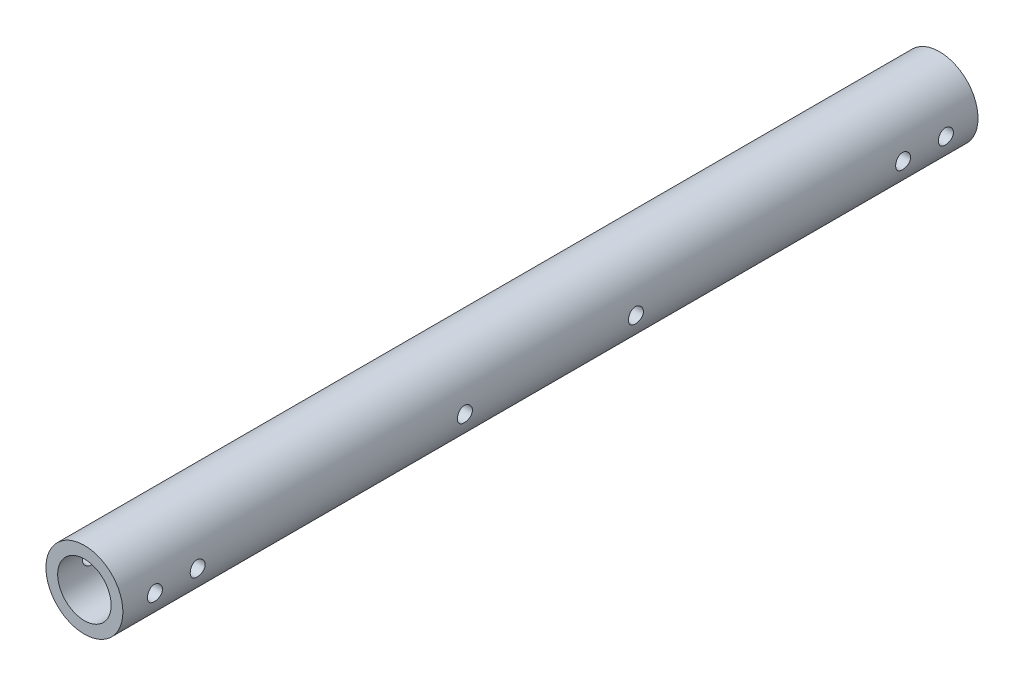
from build123d import *

# Parameters (mm, degrees)
SKETCH_1_R               = 9
SKETCH_1_R_2             = 6.25
EXTRUDE_1_DEPTH          = 200
SKETCH_2_R               = 1.75
CUT_EXTRUDE_1_DEPTH      = 10
CUT_EXTRUDE_1_DEPTH_BACK = 10


with BuildPart() as part:
    # ｽｹｯﾁ1 → ﾎﾞｽ - 押し出し1 (new body)
    with BuildSketch(Plane.XY):
        Circle(SKETCH_1_R)
        Circle(SKETCH_1_R_2, mode=Mode.SUBTRACT)
    extrude(amount=EXTRUDE_1_DEPTH)

    # ｽｹｯﾁ2 → ｶｯﾄ - 押し出し1 (cut, two sides)
    with BuildSketch(Plane(origin=(0, 0, 0), x_dir=(0, 0, -1), z_dir=(1, 0, 0))) as cut_extrude_1_sk:
        with Locations((-7.5, 0)):
            Circle(SKETCH_2_R)
        with Locations((-192.5, 0)):
            Circle(SKETCH_2_R)
        with Locations((-80, 0)):
            Circle(SKETCH_2_R)
        with Locations((-120, 0)):
            Circle(SKETCH_2_R)
        with Locations((-17.5, 0)):
            Circle(SKETCH_2_R)
        with Locations((-182.5, 0)):
            Circle(SKETCH_2_R)
    extrude(amount=CUT_EXTRUDE_1_DEPTH, mode=Mode.SUBTRACT)
    extrude(cut_extrude_1_sk.sketch, amount=-CUT_EXTRUDE_1_DEPTH_BACK, mode=Mode.SUBTRACT)


solid = part.part
